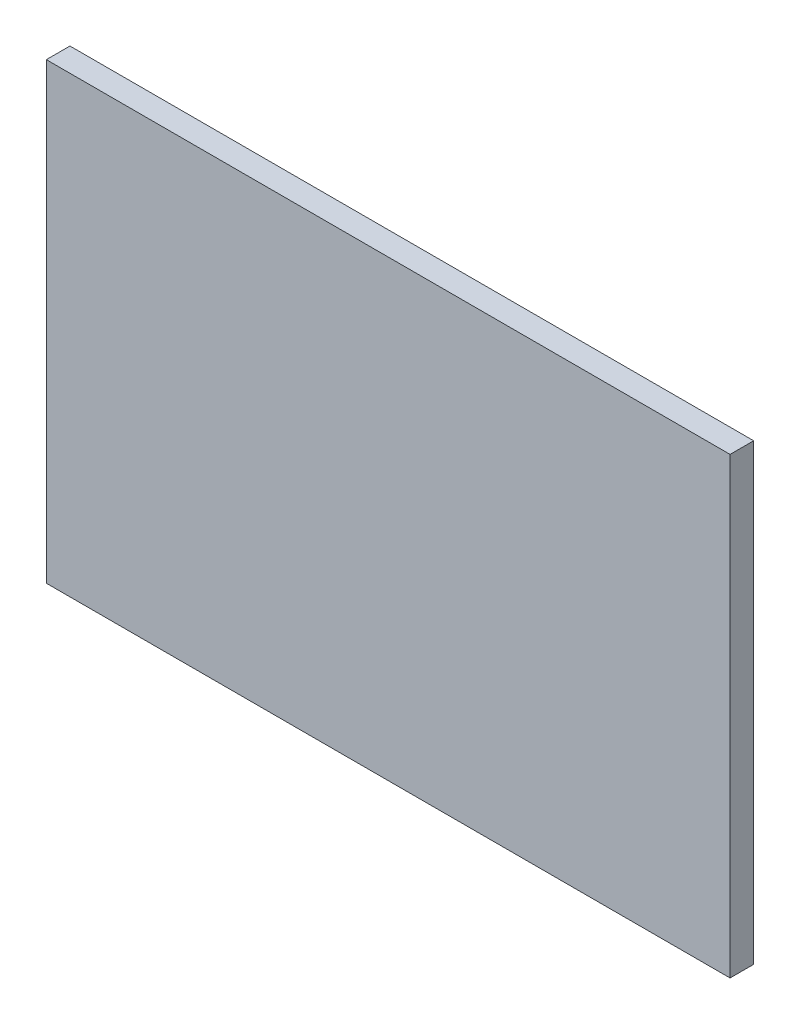
from build123d import *

# Parameters (mm, degrees)
SKETCH1_W           = 1838.325
SKETCH1_H           = 63.5
BOSS_EXTRUDE1_DEPTH = 1219.2


with BuildPart() as part:
    # Sketch1 → Boss-Extrude1 (new body)
    with BuildSketch(Plane(origin=(0, 0, 0), x_dir=(1, 0, 0), z_dir=(0, 1, 0))):
        Rectangle(SKETCH1_W, SKETCH1_H)
    extrude(amount=BOSS_EXTRUDE1_DEPTH)


solid = part.part
